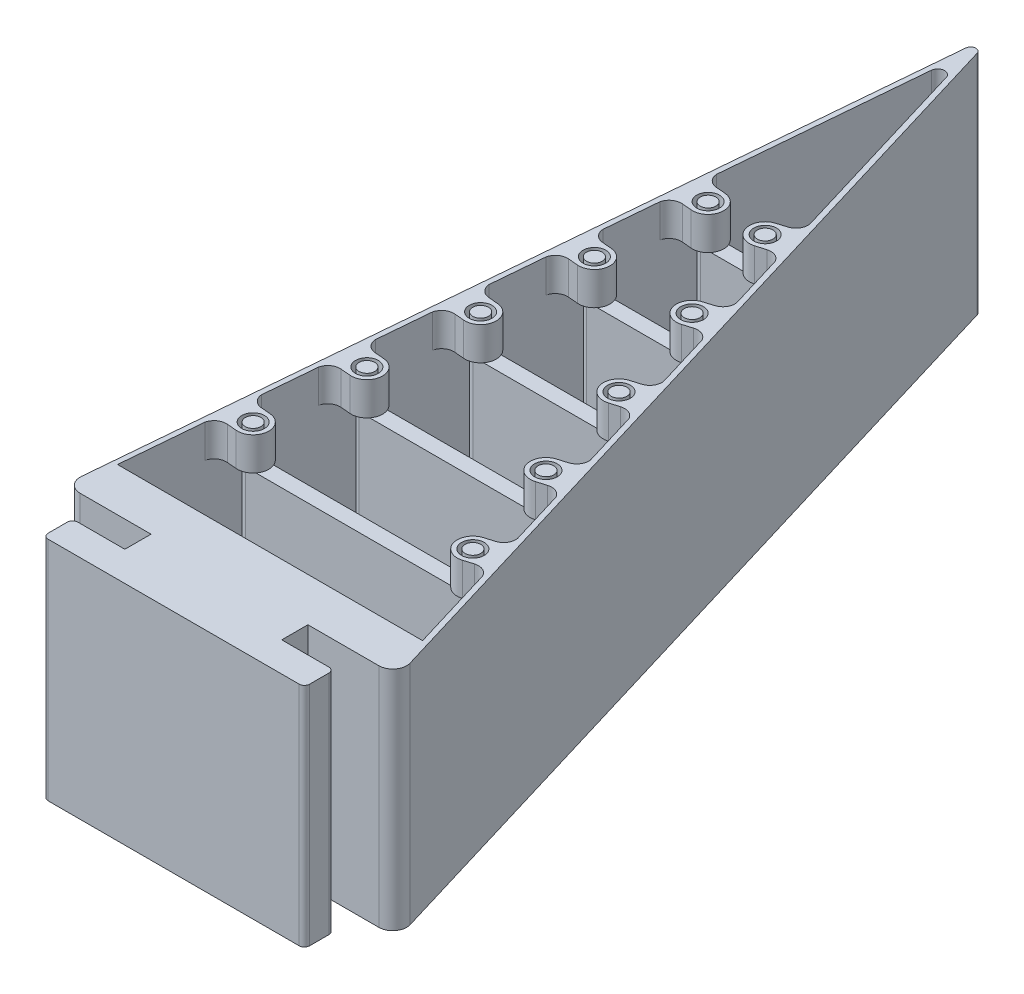
from build123d import *

# Parameters (mm, degrees)
BOSS_EXTRUDE1_DEPTH   = 26
SKETCH3_R             = 1.3
BOSS_EXTRUDE2_DEPTH   = 3.8
BOSS_EXTRUDE3_DEPTH   = 18
BOSS_EXTRUDE3_2_DEPTH = 18
BOSS_EXTRUDE3_3_DEPTH = 18
BOSS_EXTRUDE3_4_DEPTH = 18
BOSS_EXTRUDE3_5_DEPTH = 18
SKETCH5_R             = 0.9
BOSS_EXTRUDE4_DEPTH   = 4
SKETCH6_R             = 0.9
BOSS_EXTRUDE5_DEPTH   = 4
BOSS_EXTRUDE6_DEPTH   = 26


with BuildPart() as part:
    # Sketch1 → Boss-Extrude1 (new body)
    with BuildSketch(Plane(origin=(0, 0, 0), x_dir=(1, 0, 0), z_dir=(0, 1, 0))):
        with BuildLine():
            Line((-0.887553135, -3.260550812), (7.276262898, 90.052293446))
            ThreePointArc((7.276262898, 90.052293446), (7.812445765, 90.596836303), (8.448453622, 90.173146564))
            Line((8.448453622, 90.173146564), (36.512257315, -2.938275828))
            ThreePointArc((36.512257315, -2.938275828), (36.264608545, -4.354264462), (34.980326902, -5))
            Line((34.980326902, -5), (0.706358382, -5))
            ThreePointArc((0.706358382, -5), (-0.473285357, -4.480944332), (-0.887553135, -3.260550812))
        make_face()
        with BuildLine():
            Line((0, 0), (7.511441929, 85.856174123))
            ThreePointArc((7.511441929, 85.856174123), (8.226352418, 86.582231266), (9.074362894, 86.017311614))
            Line((9.074362894, 86.017311614), (35, 0))
            Line((35, 0), (0, 0))
        make_face(mode=Mode.SUBTRACT)
    extrude(amount=BOSS_EXTRUDE1_DEPTH)

    # Sketch3 → Boss-Extrude2 (add)
    with BuildSketch(Plane(origin=(0, 26, 0), x_dir=(1, 0, 0), z_dir=(0, 1, 0))):
        with BuildLine():
            Line((5.7557669, 49.890273274), (6.86588578, 49.793150457))
            ThreePointArc((6.86588578, 49.793150457), (8.5021559, 47.843119663), (6.552125106, 46.206849543))
            Line((6.552125106, 46.206849543), (5.442006226, 46.303972361))
            ThreePointArc((5.442006226, 46.303972361), (4.499197632, 46.043452712), (3.95705147, 45.229305263))
            Line((3.95705147, 45.229305263), (4.479985926, 51.206473451))
            ThreePointArc((4.479985926, 51.206473451), (4.872520449, 50.310552037), (5.7557669, 49.890273274))
        make_face()
        with Locations(Location((6.709005443, 48, 0), (0, 0, 270))):
            Circle(SKETCH3_R, mode=Mode.SUBTRACT)
        with BuildLine():
            Line((6.805630862, 61.890273274), (7.915749742, 61.793150457))
            ThreePointArc((7.915749742, 61.793150457), (9.552019862, 59.843119663), (7.601989068, 58.206849543))
            Line((7.601989068, 58.206849543), (6.491870188, 58.303972361))
            ThreePointArc((6.491870188, 58.303972361), (5.549061595, 58.043452712), (5.006915432, 57.229305263))
            Line((5.006915432, 57.229305263), (5.529849888, 63.206473451))
            ThreePointArc((5.529849888, 63.206473451), (5.922384412, 62.310552037), (6.805630862, 61.890273274))
        make_face()
        with Locations(Location((7.758869405, 60, 0), (0, 0, 270))):
            Circle(SKETCH3_R, mode=Mode.SUBTRACT)
        with BuildLine():
            Line((14.852412741, 62.04500087), (13.785462126, 61.723421714))
            ThreePointArc((13.785462126, 61.723421714), (12.581480104, 59.480560307), (14.824341512, 58.276578286))
            Line((14.824341512, 58.276578286), (15.891292127, 58.598157442))
            ThreePointArc((15.891292127, 58.598157442), (16.867422329, 58.535480801), (17.56427591, 57.849074494))
            Line((17.56427591, 57.849074494), (15.832810267, 63.593813542))
            ThreePointArc((15.832810267, 63.593813542), (15.631329309, 62.636649003), (14.852412741, 62.04500087))
        make_face()
        with Locations(Location((14.304901819, 60, 0), (0, 0, 270))):
            Circle(SKETCH3_R, mode=Mode.SUBTRACT)
        with BuildLine():
            Line((18.469215446, 50.04500087), (17.40226483, 49.723421714))
            ThreePointArc((17.40226483, 49.723421714), (16.198282809, 47.480560307), (18.441144216, 46.276578286))
            Line((18.441144216, 46.276578286), (19.508094832, 46.598157442))
            ThreePointArc((19.508094832, 46.598157442), (20.484225033, 46.535480801), (21.181078615, 45.849074494))
            Line((21.181078615, 45.849074494), (19.449612971, 51.593813542))
            ThreePointArc((19.449612971, 51.593813542), (19.248132013, 50.636649003), (18.469215446, 50.04500087))
        make_face()
        with Locations(Location((17.921704523, 48, 0), (0, 0, 270))):
            Circle(SKETCH3_R, mode=Mode.SUBTRACT)
        with BuildLine():
            Line((23.124897536, 34.598157442), (22.057946921, 34.276578286))
            ThreePointArc((22.057946921, 34.276578286), (19.815085513, 35.480560307), (21.019067534, 37.723421714))
            Line((21.019067534, 37.723421714), (22.08601815, 38.04500087))
            ThreePointArc((22.08601815, 38.04500087), (22.864934717, 38.636649003), (23.066415675, 39.593813542))
            Line((23.066415675, 39.593813542), (24.797881319, 33.849074494))
            ThreePointArc((24.797881319, 33.849074494), (24.101027738, 34.535480801), (23.124897536, 34.598157442))
        make_face()
        with Locations(Location((21.538507227, 36, 0), (0, 0, 270))):
            Circle(SKETCH3_R, mode=Mode.SUBTRACT)
        with BuildLine():
            Line((2.606175013, 13.890273274), (3.716293893, 13.793150457))
            ThreePointArc((3.716293893, 13.793150457), (5.352564013, 11.843119663), (3.402533219, 10.206849543))
            Line((3.402533219, 10.206849543), (2.292414339, 10.303972361))
            ThreePointArc((2.292414339, 10.303972361), (1.349605745, 10.043452712), (0.807459583, 9.229305263))
            Line((0.807459583, 9.229305263), (1.330394039, 15.206473451))
            ThreePointArc((1.330394039, 15.206473451), (1.722928562, 14.310552037), (2.606175013, 13.890273274))
        make_face()
        with Locations(Location((3.559413556, 12, 0), (0, 0, 270))):
            Circle(SKETCH3_R, mode=Mode.SUBTRACT)
        with BuildLine():
            Line((3.656038975, 25.890273274), (4.766157855, 25.793150457))
            ThreePointArc((4.766157855, 25.793150457), (6.402427975, 23.843119663), (4.452397182, 22.206849543))
            Line((4.452397182, 22.206849543), (3.342278301, 22.303972361))
            ThreePointArc((3.342278301, 22.303972361), (2.399469708, 22.043452712), (1.857323545, 21.229305263))
            Line((1.857323545, 21.229305263), (2.380258001, 27.206473451))
            ThreePointArc((2.380258001, 27.206473451), (2.772792525, 26.310552037), (3.656038975, 25.890273274))
        make_face()
        with Locations(Location((4.609277518, 24, 0), (0, 0, 270))):
            Circle(SKETCH3_R, mode=Mode.SUBTRACT)
        with BuildLine():
            Line((4.705902938, 37.890273274), (5.816021818, 37.793150457))
            ThreePointArc((5.816021818, 37.793150457), (7.452291937, 35.843119663), (5.502261144, 34.206849543))
            Line((5.502261144, 34.206849543), (4.392142264, 34.303972361))
            ThreePointArc((4.392142264, 34.303972361), (3.44933367, 34.043452712), (2.907187507, 33.229305263))
            Line((2.907187507, 33.229305263), (3.430121964, 39.206473451))
            ThreePointArc((3.430121964, 39.206473451), (3.822656487, 38.310552037), (4.705902938, 37.890273274))
        make_face()
        with Locations(Location((5.659141481, 36, 0), (0, 0, 270))):
            Circle(SKETCH3_R, mode=Mode.SUBTRACT)
        with BuildLine():
            Line((25.702820854, 26.04500087), (24.635870239, 25.723421714))
            ThreePointArc((24.635870239, 25.723421714), (23.431888218, 23.480560307), (25.674749625, 22.276578286))
            Line((25.674749625, 22.276578286), (26.74170024, 22.598157442))
            ThreePointArc((26.74170024, 22.598157442), (27.717830442, 22.535480801), (28.414684023, 21.849074494))
            Line((28.414684023, 21.849074494), (26.68321838, 27.593813542))
            ThreePointArc((26.68321838, 27.593813542), (26.481737422, 26.636649003), (25.702820854, 26.04500087))
        make_face()
        with Locations(Location((25.155309932, 24, 0), (0, 0, 270))):
            Circle(SKETCH3_R, mode=Mode.SUBTRACT)
        with BuildLine():
            Line((29.319623559, 14.04500087), (28.252672943, 13.723421714))
            ThreePointArc((28.252672943, 13.723421714), (27.048690922, 11.480560307), (29.291552329, 10.276578286))
            Line((29.291552329, 10.276578286), (30.358502945, 10.598157442))
            ThreePointArc((30.358502945, 10.598157442), (31.334633146, 10.535480801), (32.031486728, 9.849074494))
            Line((32.031486728, 9.849074494), (30.300021084, 15.593813542))
            ThreePointArc((30.300021084, 15.593813542), (30.098540126, 14.636649003), (29.319623559, 14.04500087))
        make_face()
        with Locations(Location((28.772112636, 12, 0), (0, 0, 270))):
            Circle(SKETCH3_R, mode=Mode.SUBTRACT)
    boss_extrude2 = extrude(amount=-BOSS_EXTRUDE2_DEPTH)

    # Mirror1: Boss-Extrude2 across plane
    add(boss_extrude2.mirror(Plane.ZX.offset(13)))

    # Sketch7 → Boss-Extrude6 (add)
    with BuildSketch(Plane(origin=(0, 26, 0), x_dir=(1, 0, 0), z_dir=(0, 1, 0))):
        with BuildLine():
            Line((26.843342642, -5), (26.843342642, -8))
            Line((26.843342642, -8), (32.243342642, -8))
            ThreePointArc((32.243342642, -8), (32.667606711, -8.175735931), (32.843342642, -8.6))
            Line((32.843342642, -8.6), (32.843342642, -10.8))
            ThreePointArc((32.843342642, -10.8), (32.667606711, -11.224264069), (32.243342642, -11.4))
            Line((32.243342642, -11.4), (3.443342642, -11.4))
            ThreePointArc((3.443342642, -11.4), (3.019078573, -11.224264069), (2.843342642, -10.8))
            Line((2.843342642, -10.8), (2.843342642, -8.6))
            ThreePointArc((2.843342642, -8.6), (3.019078573, -8.175735931), (3.443342642, -8))
            Line((3.443342642, -8), (8.843342642, -8))
            Line((8.843342642, -8), (8.843342642, -5))
            Line((8.843342642, -5), (26.843342642, -5))
        make_face()
    extrude(amount=-BOSS_EXTRUDE6_DEPTH)


with BuildPart() as body_2:
    # Sketch4 → Boss-Extrude3 (new body)
    with BuildSketch(Plane(origin=(0, 22, 0), x_dir=(1, 0, 0), z_dir=(0, 1, 0))):
        with BuildLine():
            Line((3.559413556, 12.9), (28.772112636, 12.9))
            ThreePointArc((28.772112636, 12.9), (29.672112636, 12), (28.772112636, 11.1))
            Line((28.772112636, 11.1), (3.559413556, 11.1))
            ThreePointArc((3.559413556, 11.1), (2.659413556, 12), (3.559413556, 12.9))
        make_face()
    extrude(amount=-BOSS_EXTRUDE3_DEPTH)



with BuildPart() as body_3:
    # Sketch4 → Boss-Extrude3 2 (new body)
    with BuildSketch(Plane(origin=(0, 22, 0), x_dir=(1, 0, 0), z_dir=(0, 1, 0))):
        with BuildLine():
            Line((4.609277518, 24.9), (25.155309932, 24.9))
            ThreePointArc((25.155309932, 24.9), (26.055309932, 24), (25.155309932, 23.1))
            Line((25.155309932, 23.1), (4.609277518, 23.1))
            ThreePointArc((4.609277518, 23.1), (3.709277518, 24), (4.609277518, 24.9))
        make_face()
    extrude(amount=-BOSS_EXTRUDE3_2_DEPTH)


with BuildPart() as body_4:
    # Sketch4 → Boss-Extrude3 3 (new body)
    with BuildSketch(Plane(origin=(0, 22, 0), x_dir=(1, 0, 0), z_dir=(0, 1, 0))):
        with BuildLine():
            Line((6.709005443, 48.9), (17.921704523, 48.9))
            ThreePointArc((17.921704523, 48.9), (18.821704523, 48), (17.921704523, 47.1))
            Line((17.921704523, 47.1), (6.709005443, 47.1))
            ThreePointArc((6.709005443, 47.1), (5.809005443, 48), (6.709005443, 48.9))
        make_face()
    extrude(amount=-BOSS_EXTRUDE3_3_DEPTH)


with BuildPart() as body_5:
    # Sketch4 → Boss-Extrude3 4 (new body)
    with BuildSketch(Plane(origin=(0, 22, 0), x_dir=(1, 0, 0), z_dir=(0, 1, 0))):
        with BuildLine():
            Line((5.659141481, 36.9), (21.538507227, 36.9))
            ThreePointArc((21.538507227, 36.9), (22.438507227, 36), (21.538507227, 35.1))
            Line((21.538507227, 35.1), (5.659141481, 35.1))
            ThreePointArc((5.659141481, 35.1), (4.759141481, 36), (5.659141481, 36.9))
        make_face()
    extrude(amount=-BOSS_EXTRUDE3_4_DEPTH)


with BuildPart() as body_6:
    # Sketch4 → Boss-Extrude3 5 (new body)
    with BuildSketch(Plane(origin=(0, 22, 0), x_dir=(1, 0, 0), z_dir=(0, 1, 0))):
        with BuildLine():
            Line((7.758869405, 60.9), (14.304901819, 60.9))
            ThreePointArc((14.304901819, 60.9), (15.204901819, 60), (14.304901819, 59.1))
            Line((14.304901819, 59.1), (7.758869405, 59.1))
            ThreePointArc((7.758869405, 59.1), (6.858869405, 60), (7.758869405, 60.9))
        make_face()
    extrude(amount=-BOSS_EXTRUDE3_5_DEPTH)


with BuildPart() as body_2_1:
    add(body_2.part)

    add(body_3.part)  # Boss-Extrude4 merges body 3

    add(body_4.part)  # Boss-Extrude4 merges body 4

    add(body_5.part)  # Boss-Extrude4 merges body 5

    add(body_6.part)  # Boss-Extrude4 merges body 6
    # Sketch5 → Boss-Extrude4 (add)
    with BuildSketch(Plane(origin=(0, 26, 0), x_dir=(1, 0, 0), z_dir=(0, 1, 0))):
        with Locations(Location((7.758869405, 60, 0), (0, 0, 270))):
            Circle(SKETCH5_R)
        with Locations(Location((14.304901819, 60, 0), (0, 0, 270))):
            Circle(SKETCH5_R)
        with Locations(Location((6.709005443, 48, 0), (0, 0, 270))):
            Circle(SKETCH5_R)
        with Locations(Location((17.921704523, 48, 0), (0, 0, 270))):
            Circle(SKETCH5_R)
        with Locations(Location((5.659141481, 36, 0), (0, 0, 270))):
            Circle(SKETCH5_R)
        with Locations(Location((21.538507227, 36, 0), (0, 0, 270))):
            Circle(SKETCH5_R)
        with Locations(Location((4.609277518, 24, 0), (0, 0, 270))):
            Circle(SKETCH5_R)
        with Locations(Location((3.559413556, 12, 0), (0, 0, 270))):
            Circle(SKETCH5_R)
        with Locations(Location((28.772112636, 12, 0), (0, 0, 270))):
            Circle(SKETCH5_R)
        with Locations(Location((25.155309932, 24, 0), (0, 0, 270))):
            Circle(SKETCH5_R)
    extrude(amount=-BOSS_EXTRUDE4_DEPTH)

    # Sketch6 → Boss-Extrude5 (add)
    with BuildSketch(Plane.XZ):
        with Locations(Location((5.659141481, -36, 0), (0, 0, 90))):
            Circle(SKETCH6_R)
        with Locations(Location((21.538507227, -36, 0), (0, 0, 90))):
            Circle(SKETCH6_R)
        with Locations(Location((25.155309932, -24, 0), (0, 0, 90))):
            Circle(SKETCH6_R)
        with Locations(Location((4.609277518, -24, 0), (0, 0, 90))):
            Circle(SKETCH6_R)
        with Locations(Location((3.559413556, -12, 0), (0, 0, 90))):
            Circle(SKETCH6_R)
        with Locations(Location((28.772112636, -12, 0), (0, 0, 90))):
            Circle(SKETCH6_R)
        with Locations(Location((6.709005443, -48, 0), (0, 0, 90))):
            Circle(SKETCH6_R)
        with Locations(Location((17.921704523, -48, 0), (0, 0, 90))):
            Circle(SKETCH6_R)
        with Locations(Location((14.304901819, -60, 0), (0, 0, 90))):
            Circle(SKETCH6_R)
        with Locations(Location((7.758869405, -60, 0), (0, 0, 90))):
            Circle(SKETCH6_R)
    extrude(amount=-BOSS_EXTRUDE5_DEPTH)


solid = Compound([part.part, body_2_1.part])
